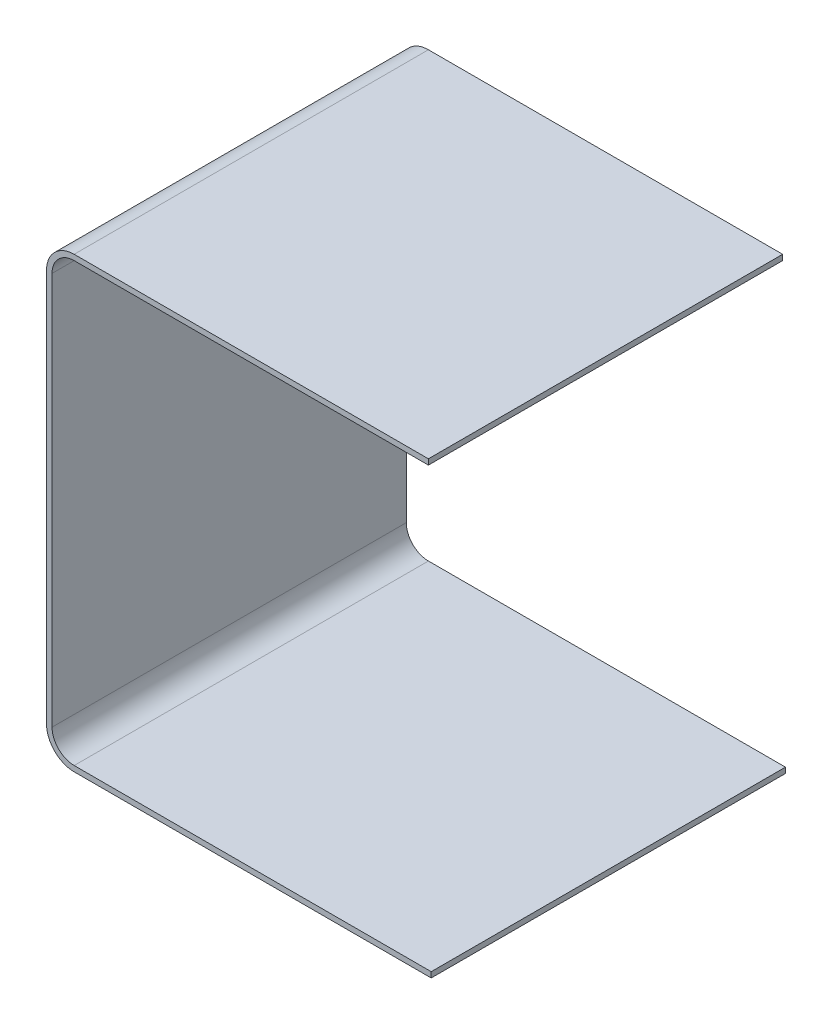
from build123d import *

# Parameters (mm, degrees)
EXTRUDE_THIN1_DEPTH = 101.6


with BuildPart() as part:
    # Sketch1 → Extrude-Thin1 (new body)
    with BuildSketch(Plane.XY):
        with BuildLine():
            Line((364.113827616, -62.70625), (261.709177451, -62.70625))
            ThreePointArc((261.709177451, -62.70625), (257.21904939, -60.846378061), (255.359177451, -56.35625))
            Line((255.359177451, -56.35625), (255.359177451, 56.35625))
            ThreePointArc((255.359177451, 56.35625), (257.21904939, 60.846378061), (261.709177451, 62.70625))
            Line((261.709177451, 62.70625), (363.309177451, 62.70625))
            Line((363.309177451, 62.70625), (363.309177451, 64.28105))
            Line((363.309177451, 64.28105), (261.709177451, 64.28105))
            ThreePointArc((261.709177451, 64.28105), (256.105497631, 61.95992982), (253.784377451, 56.35625))
            Line((253.784377451, 56.35625), (253.784377451, -56.35625))
            ThreePointArc((253.784377451, -56.35625), (256.105497631, -61.95992982), (261.709177451, -64.28105))
            Line((261.709177451, -64.28105), (364.113827616, -64.28105))
            Line((364.113827616, -64.28105), (364.113827616, -62.70625))
        make_face()
    extrude(amount=EXTRUDE_THIN1_DEPTH)


solid = part.part
